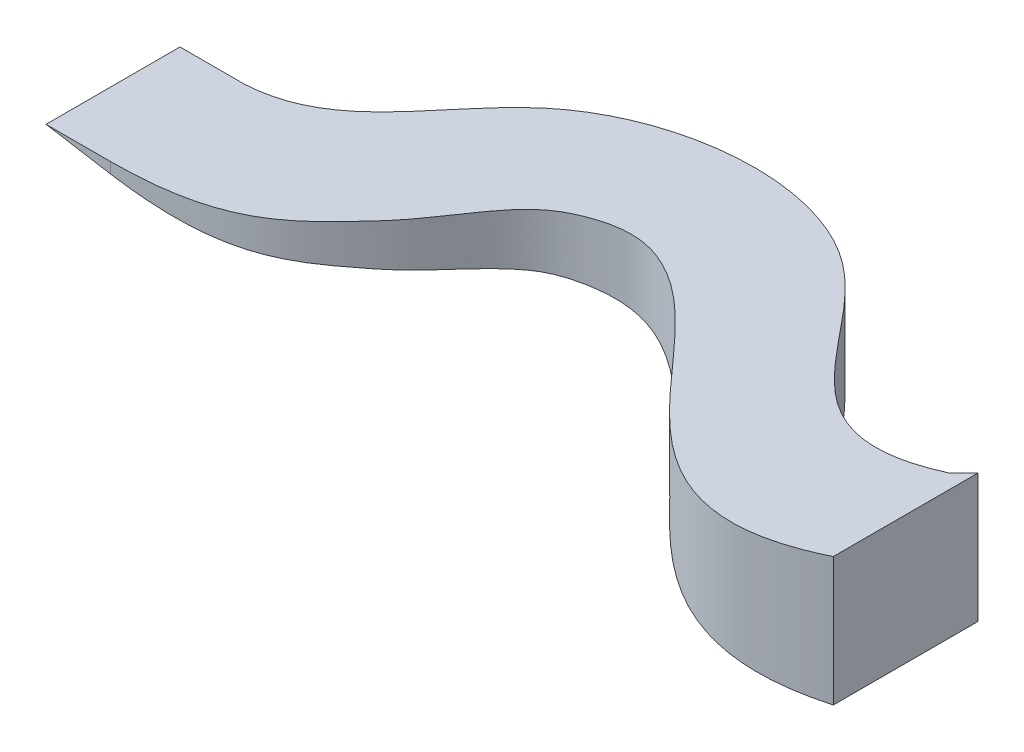
from build123d import *

# Parameters (mm, degrees)
BOSS_EXTRUDE1_DEPTH     = 600
CUT_EXTRUDE5_DEPTH      = 2000
CUT_EXTRUDE5_DEPTH_BACK = 2000


with BuildPart() as part:
    # Sketch3 → Boss-Extrude1 (new body)
    with BuildSketch(Plane(origin=(0, 0, 0), x_dir=(1, 0, 0), z_dir=(0, 1, 0))):
        with BuildLine():
            Line((103.218681112, 620), (-196.781318888, 620))
            Line((-196.781318888, 620), (-196.781318888, -5))
            Line((-196.781318888, -5), (103.218681112, -5))
            add(Edge.make_bspline(
                [(103.218681112, -5), (588.195154083, -3.163876673), (771.964594842, 163.799162942), (1094.072701401, 516.961291923), (1231.556596444, 783.162980701), (1553.46181428, 941.694369248), (2236.258983329, 839.954455387), (2563.06483301, -321.158582751), (3386.238883814, 85.06610873)],
                knots=[0, 0, 0, 0, 0.169189831, 0.199378197, 0.290494168, 0.314771929, 0.430766308, 1, 1, 1, 1], degree=3))
            Line((3386.238883814, 85.06610873), (3386.238883814, 760.246183749))
            add(Edge.make_bspline(
                [(3386.238883814, 760.246183749), (3317.035378353, 692.028174156)],
                knots=[0, 0, 1, 1], degree=1))
            add(Edge.make_bspline(
                [(3317.035378353, 692.028174156), (2719.285403286, 421.343297775), (2458.958585868, 1613.401027739), (791.345221602, 1472.71065196), (517.504039845, 642.649574707), (103.218681112, 620)],
                knots=[0, 0, 0, 0, 0.371433836, 0.717359921, 1, 1, 1, 1], degree=3))
        make_face()
    extrude(amount=BOSS_EXTRUDE1_DEPTH)

    # Sketch5 → Cut-Extrude5 (cut, two sides)
    with BuildSketch(Plane.XY) as cut_extrude5_sk:
        Polygon((3386.238883814, 0), (-196.781318888, 600), (-196.781318888, 0), align=None)
    extrude(amount=CUT_EXTRUDE5_DEPTH, mode=Mode.SUBTRACT)
    extrude(cut_extrude5_sk.sketch, amount=-CUT_EXTRUDE5_DEPTH_BACK, mode=Mode.SUBTRACT)


solid = part.part
